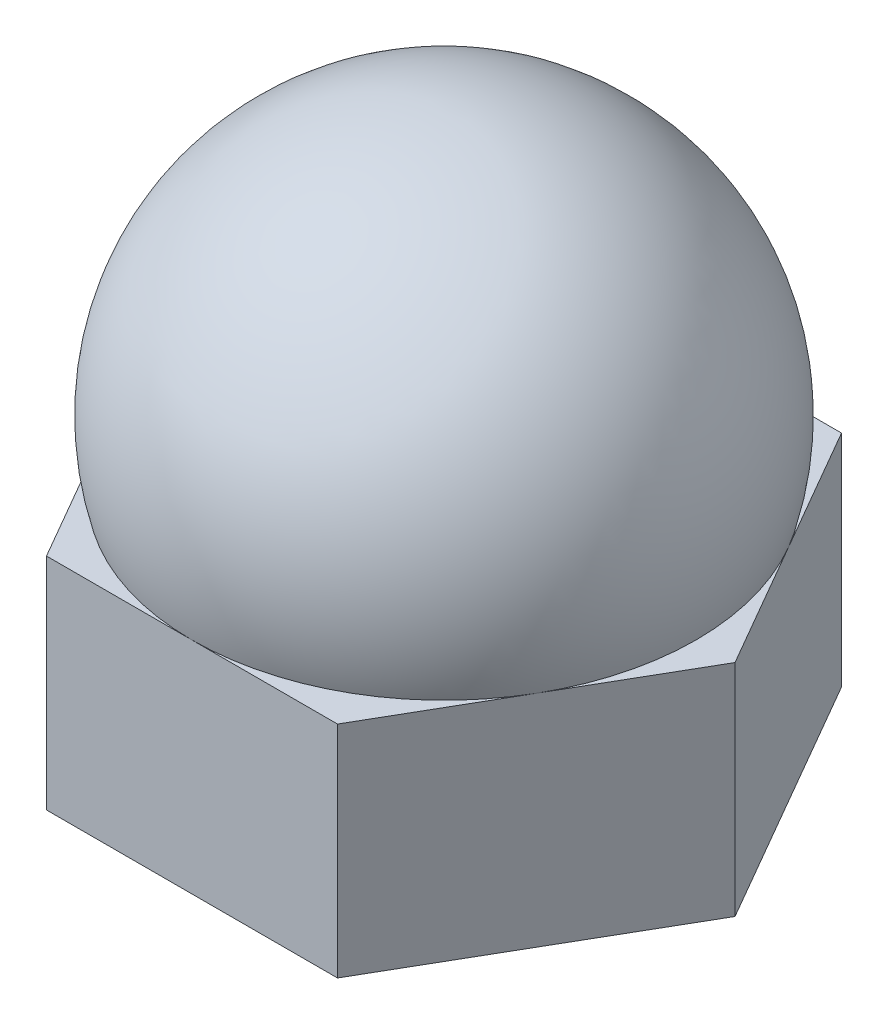
from build123d import *

# Parameters (mm, degrees)
CROQUIS1_R              = 1.25
SALIENTE_EXTRUIR1_DEPTH = 2.4


with BuildPart() as part:
    # Croquis1 → Saliente-Extruir1 (new body)
    with BuildSketch(Plane(origin=(0, 0, 0), x_dir=(1, 0, 0), z_dir=(0, 1, 0))):
        Polygon((-1.58771324, 2.75), (-3.175426481, 0), (-1.58771324, -2.75), (1.58771324, -2.75), (3.175426481, 0), (1.58771324, 2.75), align=None)
        Circle(CROQUIS1_R, mode=Mode.SUBTRACT)
    extrude(amount=SALIENTE_EXTRUIR1_DEPTH)

    # Croquis3 one side → Revolución2 (revolve)
    with BuildSketch(Plane(origin=(0, 0, 0), x_dir=(0, 0, -1), z_dir=(1, 0, 0))):
        with BuildLine():
            Line((0, 6), (0, 2.4))
            Line((0, 2.4), (2.75, 2.4))
            ThreePointArc((2.75, 2.4), (2.265088298, 4.879928561), (0, 6))
        make_face()
    revolve(axis=Axis((0, 6, 0), (0, -1, 0)))


solid = part.part
